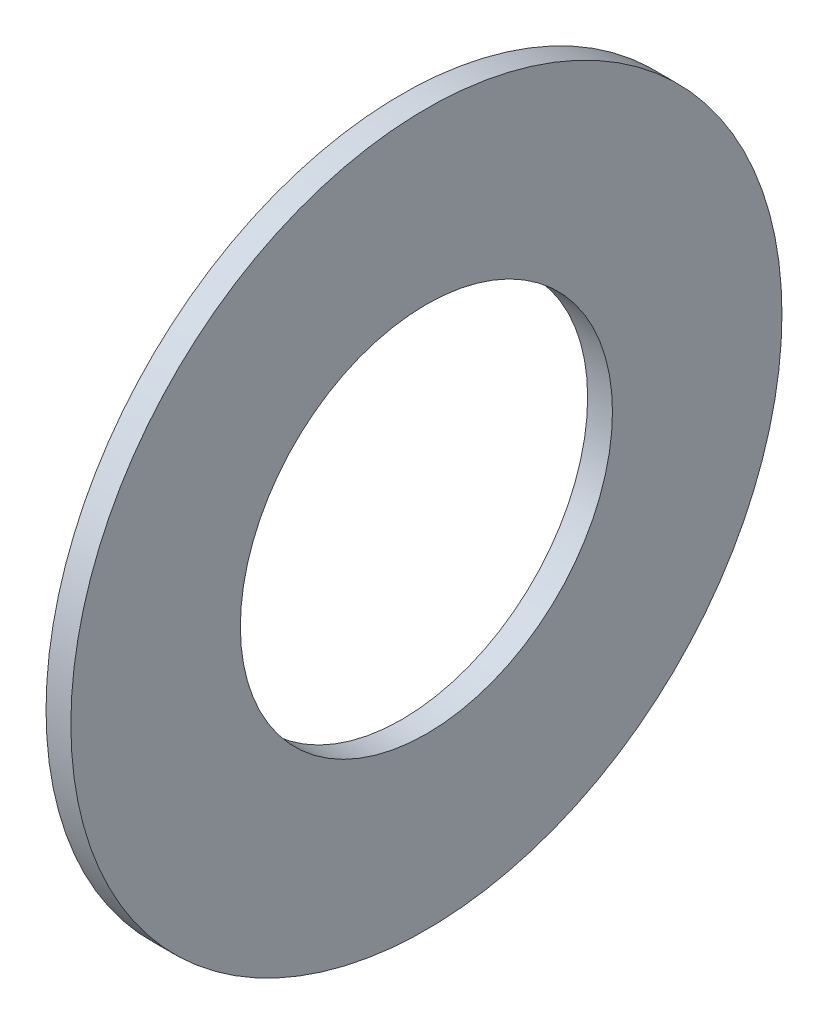
from build123d import *

# Parameters (mm, degrees)
SKETCH1_W = 3
SKETCH1_H = 20.5


with BuildPart() as part:
    # Sketch1 → Revolve1 (revolve)
    with BuildSketch(Plane.XY):
        with Locations((-33.091093128, 30.656172878)):
            Rectangle(SKETCH1_W, SKETCH1_H)
    revolve(axis=Axis((-20.262687395, -2.093827122, 0), (1, 0, 0)))


solid = part.part
